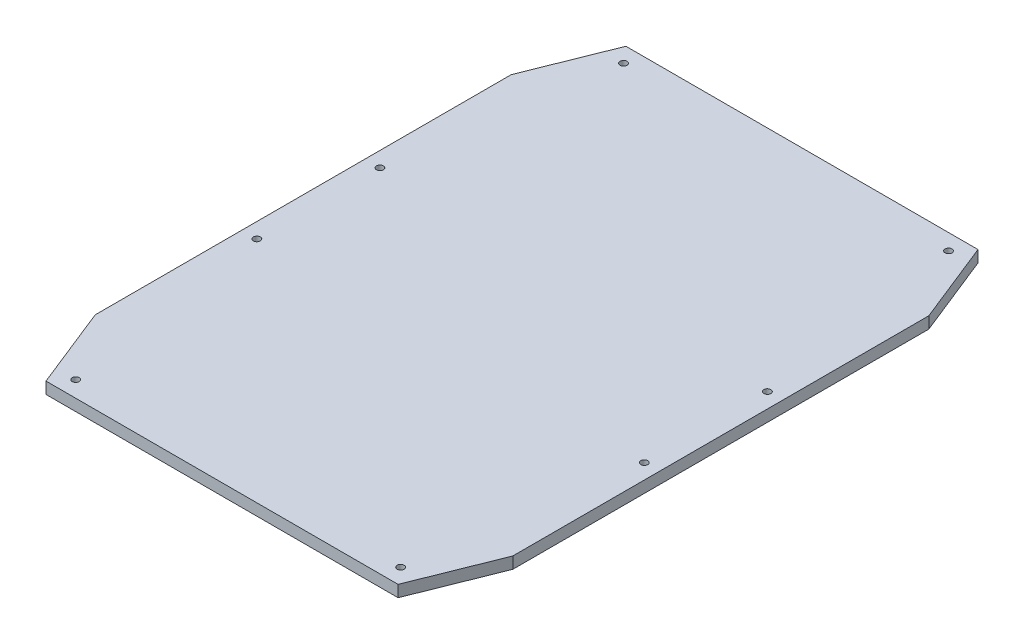
from build123d import *

# Parameters (mm, degrees)
BOSS_EXTRUDE1_DEPTH = 5
SKETCH2_R           = 1.5
CUT_EXTRUDE1_DEPTH  = 10


with BuildPart() as part:
    # Sketch1 → Boss-Extrude1 (new body)
    with BuildSketch(Plane(origin=(0, 0, 0), x_dir=(1, 0, 0), z_dir=(0, 1, 0))):
        Polygon((0, 0), (151.72, 0), (165.843118786, 35.310315996), (165.843118786, 214.600315996), (151.72, 249.910631993), (0, 249.910631993), (-14.123118786, 214.600315996), (-14.123118786, 35.310315996), align=None)
    extrude(amount=BOSS_EXTRUDE1_DEPTH)

    # Sketch2 → Cut-Extrude1 (cut)
    with BuildSketch(Plane(origin=(0, 5, 0), x_dir=(1, 0, 0), z_dir=(0, 1, 0))):
        with Locations((159.339988978, 98.477853355)):
            Circle(SKETCH2_R)
        with Locations((145.883373815, 6.952127765)):
            Circle(SKETCH2_R)
        with Locations((5.840897433, 6.952127765)):
            Circle(SKETCH2_R)
        with Locations((-7.615717731, 98.477853355)):
            Circle(SKETCH2_R)
        with Locations((-7.615717731, 151.522146645)):
            Circle(SKETCH2_R)
        with Locations((5.840897433, 243.047872235)):
            Circle(SKETCH2_R)
        with Locations((145.883373815, 243.047872235)):
            Circle(SKETCH2_R)
        with Locations((159.339988978, 151.522146645)):
            Circle(SKETCH2_R)
    extrude(amount=-CUT_EXTRUDE1_DEPTH, mode=Mode.SUBTRACT)


solid = part.part
